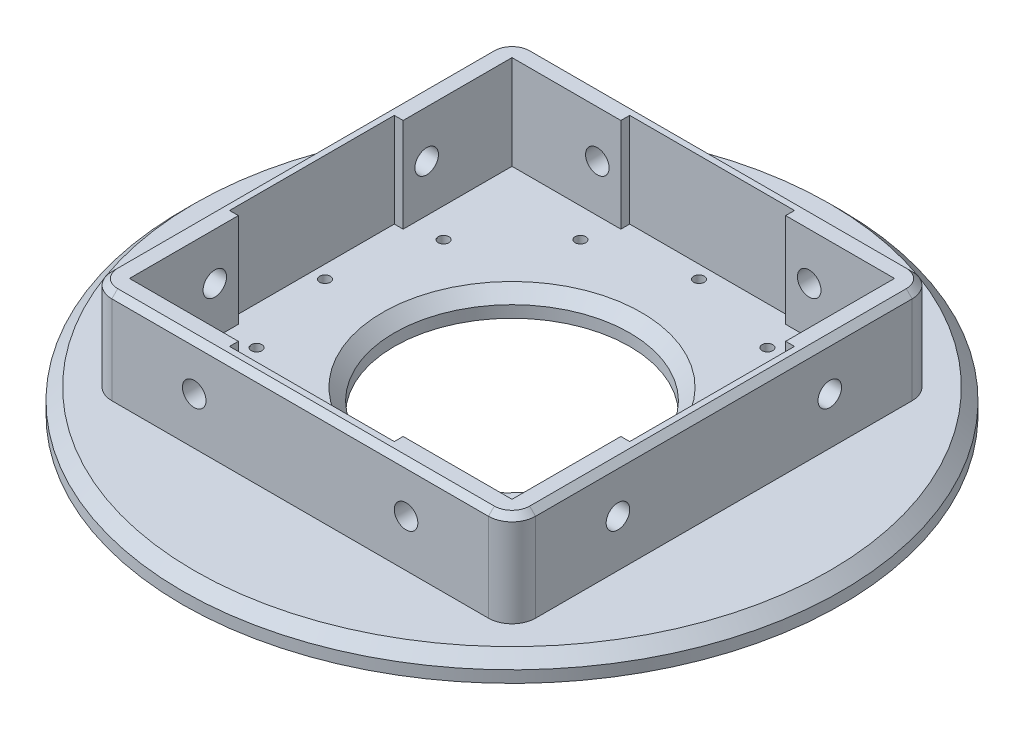
from build123d import *

# Parameters (mm, degrees)
SKETCH1_R               = 1.4351
SKETCH1_R_2             = 31.75
BOSS_EXTRUDE1_DEPTH     = 6.35
SKETCH1_R_3             = 88.9
SKETCH1_W               = 114.3
SKETCH1_H               = 114.3
BOSS_EXTRUDE1_2_DEPTH   = 6.35
SKETCH1_3_W             = 114.3
SKETCH1_3_H             = 114.3
BOSS_EXTRUDE2_DEPTH     = 31.75
CUT_EXTRUDE1_DEPTH      = 130.67066939
CUT_EXTRUDE1_DEPTH_BACK = 130.67066939
SKETCH3_R               = 3.175
CUT_EXTRUDE2_DEPTH      = 130.67066939
CUT_EXTRUDE2_DEPTH_BACK = 130.67066939
SKETCH4_R               = 3.175
FILLET1_R               = 6.35
CHAMFER1_SIZE           = 3.175
CHAMFER2_SIZE           = 1.5875


with BuildPart() as part:
    # Sketch1 → Boss-Extrude1 (new body)
    with BuildSketch(Plane(origin=(0, 0, 0), x_dir=(1, 0, 0), z_dir=(0, 1, 0))):
        Polygon((-22.225, -51.59375), (-22.225, -53.975), (22.225, -53.975), (22.225, -51.59375), (51.59375, -51.59375), (51.59375, -22.225), (53.975, -22.225), (53.975, 22.225), (51.59375, 22.225), (51.59375, 51.59375), (22.225, 51.59375), (22.225, 53.975), (-22.225, 53.975), (-22.225, 51.59375), (-51.59375, 51.59375), (-51.59375, 22.225), (-53.975, 22.225), (-53.975, -22.225), (-51.59375, -22.225), (-51.59375, -51.59375), align=None)
        with Locations((-50.4444, 0)):
            Circle(SKETCH1_R, mode=Mode.SUBTRACT)
        with Locations((-25.2222, -43.686131879)):
            Circle(SKETCH1_R, mode=Mode.SUBTRACT)
        with Locations((-43.686131879, -25.2222)):
            Circle(SKETCH1_R, mode=Mode.SUBTRACT)
        with Locations((0, -50.4444)):
            Circle(SKETCH1_R, mode=Mode.SUBTRACT)
        with Locations((25.2222, -43.686131879)):
            Circle(SKETCH1_R, mode=Mode.SUBTRACT)
        with Locations((43.686131879, -25.2222)):
            Circle(SKETCH1_R, mode=Mode.SUBTRACT)
        with Locations((-43.686131879, 25.2222)):
            Circle(SKETCH1_R, mode=Mode.SUBTRACT)
        with Locations((-25.2222, 43.686131879)):
            Circle(SKETCH1_R, mode=Mode.SUBTRACT)
        Circle(SKETCH1_R_2, mode=Mode.SUBTRACT)
        with Locations((43.686131879, 25.2222)):
            Circle(SKETCH1_R, mode=Mode.SUBTRACT)
        with Locations((25.2222, 43.686131879)):
            Circle(SKETCH1_R, mode=Mode.SUBTRACT)
        with Locations((50.4444, 0)):
            Circle(SKETCH1_R, mode=Mode.SUBTRACT)
        with Locations((0, 50.4444)):
            Circle(SKETCH1_R, mode=Mode.SUBTRACT)
    extrude(amount=BOSS_EXTRUDE1_DEPTH)



with BuildPart() as body_2:
    # Sketch1 → Boss-Extrude1 2 (new body)
    with BuildSketch(Plane(origin=(0, 0, 0), x_dir=(1, 0, 0), z_dir=(0, 1, 0))):
        Circle(SKETCH1_R_3)
        Rectangle(SKETCH1_W, SKETCH1_H, mode=Mode.SUBTRACT)
    extrude(amount=BOSS_EXTRUDE1_2_DEPTH)


with BuildPart() as part_1:
    add(part.part)

    add(body_2.part)  # Boss-Extrude2 merges body 2
    # Sketch1_3 → Boss-Extrude2 (add)
    with BuildSketch(Plane(origin=(0, 0, 0), x_dir=(1, 0, 0), z_dir=(0, 1, 0))):
        Rectangle(SKETCH1_3_W, SKETCH1_3_H)
        Polygon((22.225, -53.975), (-22.225, -53.975), (-22.225, -51.59375), (-51.59375, -51.59375), (-51.59375, -22.225), (-53.975, -22.225), (-53.975, 22.225), (-51.59375, 22.225), (-51.59375, 51.59375), (-22.225, 51.59375), (-22.225, 53.975), (22.225, 53.975), (22.225, 51.59375), (51.59375, 51.59375), (51.59375, 22.225), (53.975, 22.225), (53.975, -22.225), (51.59375, -22.225), (51.59375, -51.59375), (22.225, -51.59375), align=None, mode=Mode.SUBTRACT)
    extrude(amount=BOSS_EXTRUDE2_DEPTH)

    # Sketch3 → Cut-Extrude1 (cut, two sides: drawn at the far end of the back side and taken through both)
    with BuildSketch(Plane.XY.offset(-CUT_EXTRUDE1_DEPTH_BACK)):
        with Locations((-28.575, 19.05)):
            Circle(SKETCH3_R)
        with Locations((28.575, 19.05)):
            Circle(SKETCH3_R)
    extrude(amount=CUT_EXTRUDE1_DEPTH + CUT_EXTRUDE1_DEPTH_BACK, mode=Mode.SUBTRACT)

    # Sketch4 → Cut-Extrude2 (cut, two sides: drawn at the far end of the back side and taken through both)
    with BuildSketch(Plane(origin=(0, 0, 0), x_dir=(0, 0, -1), z_dir=(1, 0, 0)).offset(-CUT_EXTRUDE2_DEPTH_BACK)):
        with Locations((-28.575, 19.05)):
            Circle(SKETCH4_R)
        with Locations((28.575, 19.05)):
            Circle(SKETCH4_R)
    extrude(amount=CUT_EXTRUDE2_DEPTH + CUT_EXTRUDE2_DEPTH_BACK, mode=Mode.SUBTRACT)

    # Fillet1
    fillet1_edges = [part_1.edges().sort_by_distance(p)[0] for p in [
        (-57.15, 19.05, 57.15),
        (-57.15, 19.05, -57.15),
        (57.15, 19.05, -57.15),
        (57.15, 19.05, 57.15),
    ]]
    fillet(fillet1_edges, radius=FILLET1_R)

    # Chamfer1
    chamfer1_edges = [part_1.edges().sort_by_distance(p)[0] for p in [
        (-88.9, 6.35, 0),
        (-31.75, 6.35, 0),
    ]]
    chamfer(chamfer1_edges, length=CHAMFER1_SIZE)

    # Chamfer2
    chamfer2_edges = [part_1.edges().sort_by_distance(p)[0] for p in [
        (0, 31.75, -57.15),
        (-55.290128061, 31.75, -55.290128061),
        (55.290128061, 31.75, -55.290128061),
        (-57.15, 31.75, 0),
        (57.15, 31.75, 0),
        (-55.290128061, 31.75, 55.290128061),
        (55.290128061, 31.75, 55.290128061),
        (0, 31.75, 57.15),
    ]]
    chamfer(chamfer2_edges, length=CHAMFER2_SIZE)


solid = part_1.part
